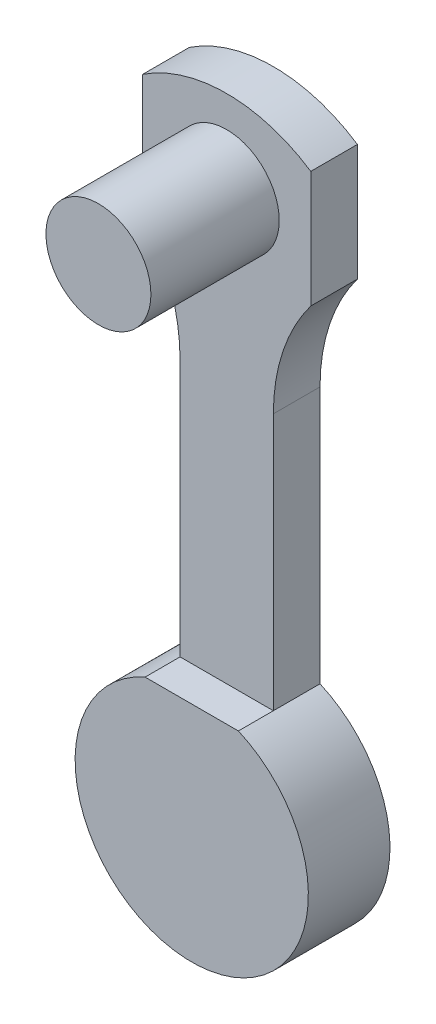
from build123d import *

# Parameters (mm, degrees)
ESTRUSIONE_ESTRUSIONE1_DEPTH      = 5
ESTRUSIONE_ESTRUSIONE1_DEPTH_BACK = 2
SCHIZZO4_R                        = 4.5
ESTRUSIONE_ESTRUSIONE3_DEPTH      = 8
SCHIZZO5_W                        = 10
SCHIZZO5_H                        = 10
TAGLIO_ESTRUSIONE1_DEPTH          = 6
SCHIZZO6_W                        = 5.883874728
SCHIZZO6_H                        = 31.765714376
TAGLIO_ESTRUSIONE3_DEPTH          = 15
TAGLIO_ESTRUSIONE3_DEPTH_BACK     = 15
SCHIZZO7_R                        = 4.5
TAGLIO_ESTRUSIONE4_DEPTH          = 3


with BuildPart() as part:
    # Schizzo1 → Estrusione-Estrusione1 (new body, two sides)
    with BuildSketch(Plane.XY) as estrusione_estrusione1_sk:
        with BuildLine():
            Line((-19.735743023, 33.889071348), (-19.735743023, 43.889071348))
            ThreePointArc((-19.735743023, 43.889071348), (-12.529677135, 46.069061439), (-5.323611247, 43.889071348))
            Line((-5.323611247, 43.889071348), (-5.323611247, 33.889071348))
            ThreePointArc((-5.323611247, 33.889071348), (-7.707011318, 29.345426307), (-8.529677135, 24.280988816))
            Line((-8.529677135, 24.280988816), (-8.529677135, 2.230988816))
            ThreePointArc((-8.529677135, 2.230988816), (-12.529677135, -16.934162574), (-16.529677135, 2.230988816))
            Line((-16.529677135, 2.230988816), (-16.529677135, 24.280988816))
            ThreePointArc((-16.529677135, 24.280988816), (-17.352342952, 29.345426307), (-19.735743023, 33.889071348))
        make_face()
    extrude(amount=ESTRUSIONE_ESTRUSIONE1_DEPTH)
    extrude(estrusione_estrusione1_sk.sketch, amount=-ESTRUSIONE_ESTRUSIONE1_DEPTH_BACK)

    # Schizzo4 → Estrusione-Estrusione3 (add)
    with BuildSketch(Plane.XY.offset(5)):
        with Locations((-12.529677135, 38.889071348)):
            Circle(SCHIZZO4_R)
    extrude(amount=ESTRUSIONE_ESTRUSIONE3_DEPTH)

    # Schizzo5 → Taglio-Estrusione1 (cut)
    with BuildSketch(Plane(origin=(0, 0, -2), x_dir=(-1, 0, 0), z_dir=(0, 0, -1))):
        with Locations((12.529677135, -6.934162574)):
            Rectangle(SCHIZZO5_W, SCHIZZO5_H)
    extrude(amount=-TAGLIO_ESTRUSIONE1_DEPTH, mode=Mode.SUBTRACT)

    # Schizzo6 → Taglio-Estrusione3 (cut, two sides)
    with BuildSketch(Plane.ZY.offset(16.529677135)) as taglio_estrusione3_sk:
        with Locations((4.941937364, 18.113846004)):
            Rectangle(SCHIZZO6_W, SCHIZZO6_H)
    extrude(amount=TAGLIO_ESTRUSIONE3_DEPTH, mode=Mode.SUBTRACT)
    extrude(taglio_estrusione3_sk.sketch, amount=-TAGLIO_ESTRUSIONE3_DEPTH_BACK, mode=Mode.SUBTRACT)

    # Schizzo7 → Taglio-Estrusione4 (cut)
    with BuildSketch(Plane.XY.offset(5)):
        Polygon((-26.342217031, 45.266793591), (-24.610237107, 33.489330106), (-19.735743023, 33.889071348), (-1.055310137, 33.889071348), (-1.98835975, 45.266793591), (-13.868873062, 49.75887888), align=None)
        with Locations((-12.529677135, 38.889071348)):
            Circle(SCHIZZO7_R, mode=Mode.SUBTRACT)
    extrude(amount=-TAGLIO_ESTRUSIONE4_DEPTH, mode=Mode.SUBTRACT)


solid = part.part
